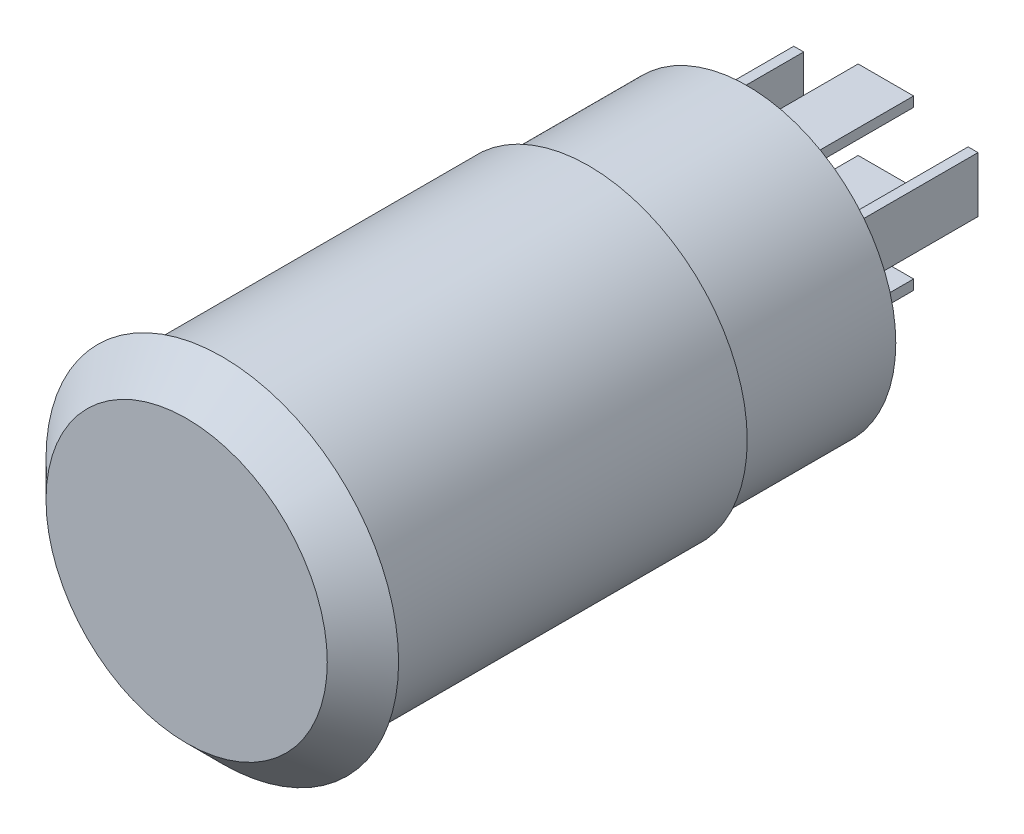
from build123d import *

# Parameters (mm, degrees)
SKETCH_1_R          = 8.9
EXTRUDE_1_DEPTH     = 1.8
EXTRUDE_1_TAPER     = 45
SKETCH_2_R          = 8
EXTRUDE_2_DEPTH     = 26.5
SKETCH_3_W          = 2.8
SKETCH_3_H          = 0.5
SKETCH_3_W_2        = 0.5
SKETCH_3_H_2        = 2.8
EXTRUDE_1_2_DEPTH   = 7
SKETCH_4_R          = 8
SKETCH_4_R_2        = 7.5
CUT_EXTRUDE_1_DEPTH = 8


with BuildPart() as part:
    # 草图1 → Extrude 1 (new body)
    with BuildSketch(Plane.XY):
        Circle(SKETCH_1_R)
    extrude(amount=EXTRUDE_1_DEPTH, taper=EXTRUDE_1_TAPER)

    # 草图2 → 凸台-拉伸2 (add)
    with BuildSketch(Plane(origin=(0, 0, 0), x_dir=(-1, 0, 0), z_dir=(0, 0, -1))):
        Circle(SKETCH_2_R)
    extrude(amount=EXTRUDE_2_DEPTH)

    # 草图3 → Extrude 1 2 (add)
    with BuildSketch(Plane(origin=(0, 0, -26.5), x_dir=(-1, 0, 0), z_dir=(0, 0, -1))):
        Rectangle(SKETCH_3_W, SKETCH_3_H)
        with Locations((0, 4)):
            Rectangle(SKETCH_3_W, SKETCH_3_H)
        with Locations((0, -4)):
            Rectangle(SKETCH_3_W, SKETCH_3_H)
        with Locations((-4.4, 2)):
            Rectangle(SKETCH_3_W_2, SKETCH_3_H_2)
        with Locations((4.4, 2)):
            Rectangle(SKETCH_3_W_2, SKETCH_3_H_2)
    extrude(amount=EXTRUDE_1_2_DEPTH)

    # 草图4 → 切除-拉伸-薄壁1 (cut)
    with BuildSketch(Plane(origin=(0, 0, -26.5), x_dir=(-1, 0, 0), z_dir=(0, 0, -1))):
        Circle(SKETCH_4_R)
        Circle(SKETCH_4_R_2, mode=Mode.SUBTRACT)
    extrude(amount=-CUT_EXTRUDE_1_DEPTH, mode=Mode.SUBTRACT)


solid = part.part
